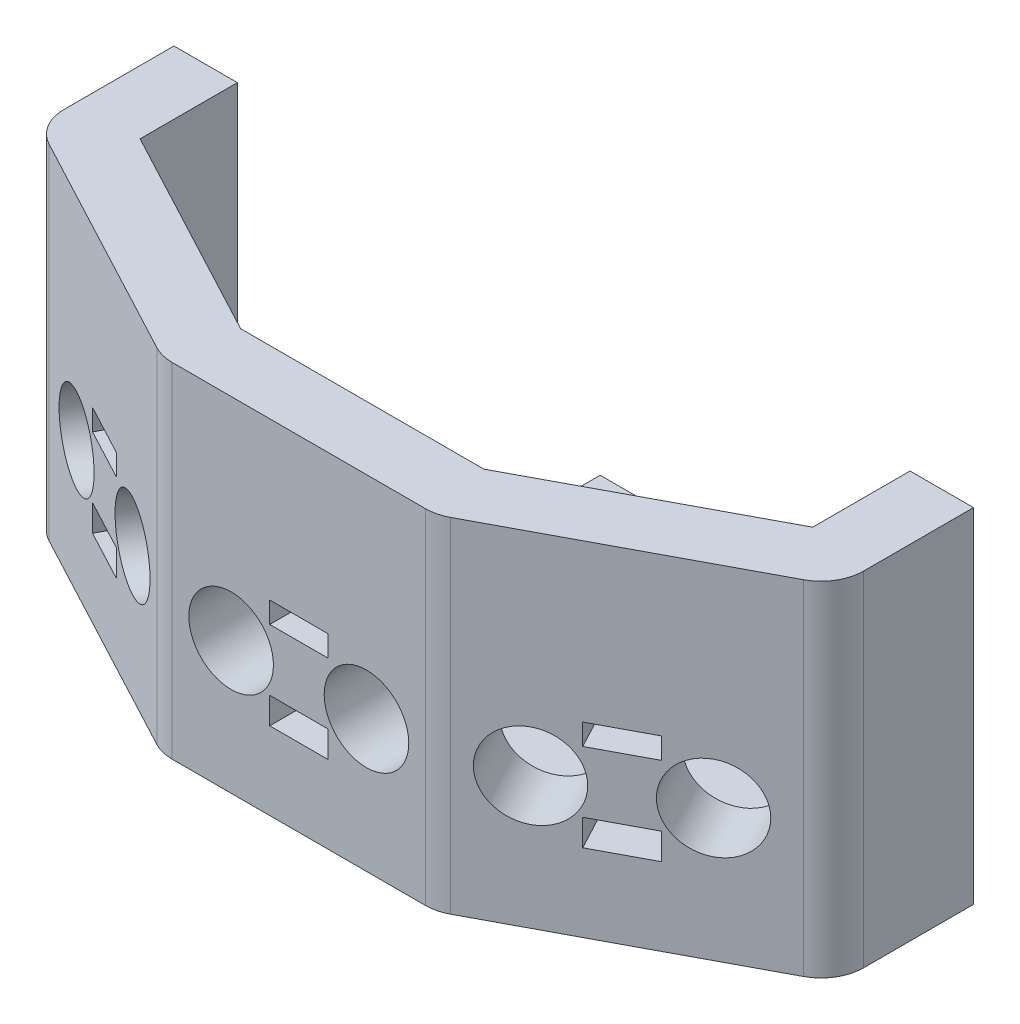
from build123d import *

# Parameters (mm, degrees)
SKETCH1_W                       = 40
SKETCH1_H                       = 25
BOSS_EXTRUDE1_DEPTH             = 10
BOSS_EXTRUDE2_DEPTH             = 10
EXTRUDE_THIN1_DEPTH             = 30
EXTRUDE_THIN1_DEPTH_BACK        = 10
FILLET1_R                       = 8
SKETCH4_R                       = 8
SKETCH4_W                       = 11
SKETCH4_H                       = 5
SKETCH4_H_2                     = 4
CUT_EXTRUDE1_DEPTH              = 30
CIRPATTERN1_COUNT               = 2
CIRPATTERN1_ANGLE               = 28
CIRPATTERN1_THE_OTHER_WAY_COUNT = 2
CIRPATTERN1_THE_OTHER_WAY_ANGLE = 28
BOSS_EXTRUDE3_DEPTH             = 25
SKETCH7_R                       = 2
CUT_EXTRUDE2_DEPTH              = 11


with BuildPart() as part:
    # Sketch1 → Boss-Extrude1 (new body)
    with BuildSketch(Plane(origin=(0, 0, 0), x_dir=(1, 0, 0), z_dir=(0, 1, 0))):
        with Locations((20, 12.5)):
            Rectangle(SKETCH1_W, SKETCH1_H)
    extrude(amount=BOSS_EXTRUDE1_DEPTH)

    # Sketch2 → Boss-Extrude2 (add)
    with BuildSketch(Plane(origin=(0, 10, 0), x_dir=(1, 0, 0), z_dir=(0, 1, 0))):
        Polygon((43, -40), (-3, -40), (-43.615589272, -18.404308112), (-43.615589272, 0), (0, 0), (40, 0), (83.615589272, 0), (83.615589272, -18.404308112), align=None)
    extrude(amount=-BOSS_EXTRUDE2_DEPTH)

    # Sketch3 → Extrude-Thin1 (add, two sides)
    with BuildSketch(Plane(origin=(0, 10, 0), x_dir=(1, 0, 0), z_dir=(0, 1, 0))) as extrude_thin1_sk:
        Polygon((-43.615589272, 0), (-43.615589272, -18.404308112), (-3, -40), (43, -40), (83.615589272, -18.404308112), (83.615589272, 0), (95.615589272, 0), (95.615589272, -25.61463554), (45.991936034, -52), (-5.991936034, -52), (-55.615589272, -25.61463554), (-55.615589272, 0), align=None)
    extrude(amount=EXTRUDE_THIN1_DEPTH)
    extrude(extrude_thin1_sk.sketch, amount=-EXTRUDE_THIN1_DEPTH_BACK)

    # Fillet1
    fillet1_edges = [part.edges().sort_by_distance(p)[0] for p in [
        (95.615589272, 20, 25.61463554),
        (45.991936034, 20, 52),
        (-5.991936034, 20, 52),
        (-55.615589272, 20, 25.61463554),
    ]]
    fillet(fillet1_edges, radius=FILLET1_R)

    # Sketch4 → Cut-Extrude1 (cut)
    with BuildSketch(Plane(origin=(0, 0, 40), x_dir=(-1, 0, 0), z_dir=(0, 0, -1))):
        with Locations((-32.8, 25)):
            Circle(SKETCH4_R)
        with Locations((-7.2, 25)):
            Circle(SKETCH4_R)
        with Locations((-20, 17.2)):
            Rectangle(SKETCH4_W, SKETCH4_H)
        with Locations((-20, 33.3)):
            Rectangle(SKETCH4_W, SKETCH4_H_2)
    cut_extrude1 = extrude(amount=-CUT_EXTRUDE1_DEPTH, mode=Mode.SUBTRACT)

    # CirPattern1: Cut-Extrude1 ×2 about axis
    cirpattern1_axis = Axis((20, 40, -52.247961471), (0, 1, 0))
    for i in range(1, CIRPATTERN1_COUNT):
        add(cut_extrude1.rotate(cirpattern1_axis, i * CIRPATTERN1_ANGLE / (CIRPATTERN1_COUNT - 1)), mode=Mode.SUBTRACT)

    # CirPattern1 the other way: Cut-Extrude1 ×2 about axis
    cirpattern1_the_other_way_axis = Axis((20, 40, -52.247961471), (0, -1, 0))
    for i in range(1, CIRPATTERN1_THE_OTHER_WAY_COUNT):
        add(cut_extrude1.rotate(cirpattern1_the_other_way_axis, i * CIRPATTERN1_THE_OTHER_WAY_ANGLE / (CIRPATTERN1_THE_OTHER_WAY_COUNT - 1)), mode=Mode.SUBTRACT)

    # Sketch6 → Boss-Extrude3 (add)
    with BuildSketch(Plane(origin=(0, 40, 0), x_dir=(1, 0, 0), z_dir=(0, 1, 0))):
        with BuildLine():
            Line((47.753084514, -51.063580743), (91.371361774, -27.871331331))
            ThreePointArc((91.371361774, -27.871331331), (94.472927677, -24.928055187), (95.615589272, -20.807750588))
            Line((95.615589272, -20.807750588), (95.615589272, 0))
            Line((95.615589272, 0), (83.615589272, 0))
            Line((83.615589272, 0), (83.615589272, -18.404308112))
            Line((83.615589272, -18.404308112), (43, -40))
            Line((43, -40), (-3, -40))
            Line((-3, -40), (-43.615589272, -18.404308112))
            Line((-43.615589272, -18.404308112), (-43.615589272, 0))
            Line((-43.615589272, 0), (-55.615589272, 0))
            Line((-55.615589272, 0), (-55.615589272, -20.807750588))
            ThreePointArc((-55.615589272, -20.807750588), (-54.472927677, -24.928055187), (-51.371361774, -27.871331331))
            Line((-51.371361774, -27.871331331), (-7.753084514, -51.063580743))
            ThreePointArc((-7.753084514, -51.063580743), (-5.932687176, -51.76236581), (-3.997312011, -52))
            Line((-3.997312011, -52), (43.997312011, -52))
            ThreePointArc((43.997312011, -52), (45.932687176, -51.76236581), (47.753084514, -51.063580743))
        make_face()
    extrude(amount=BOSS_EXTRUDE3_DEPTH)

    # Sketch7 → Cut-Extrude2 (cut, through all)
    with BuildSketch(Plane(origin=(0, 10, 0), x_dir=(1, 0, 0), z_dir=(0, 1, 0))):
        with Locations((10, 12.5)):
            Circle(SKETCH7_R)
        with Locations((30, 12.5)):
            Circle(SKETCH7_R)
    extrude(amount=-CUT_EXTRUDE2_DEPTH, mode=Mode.SUBTRACT)


solid = part.part
